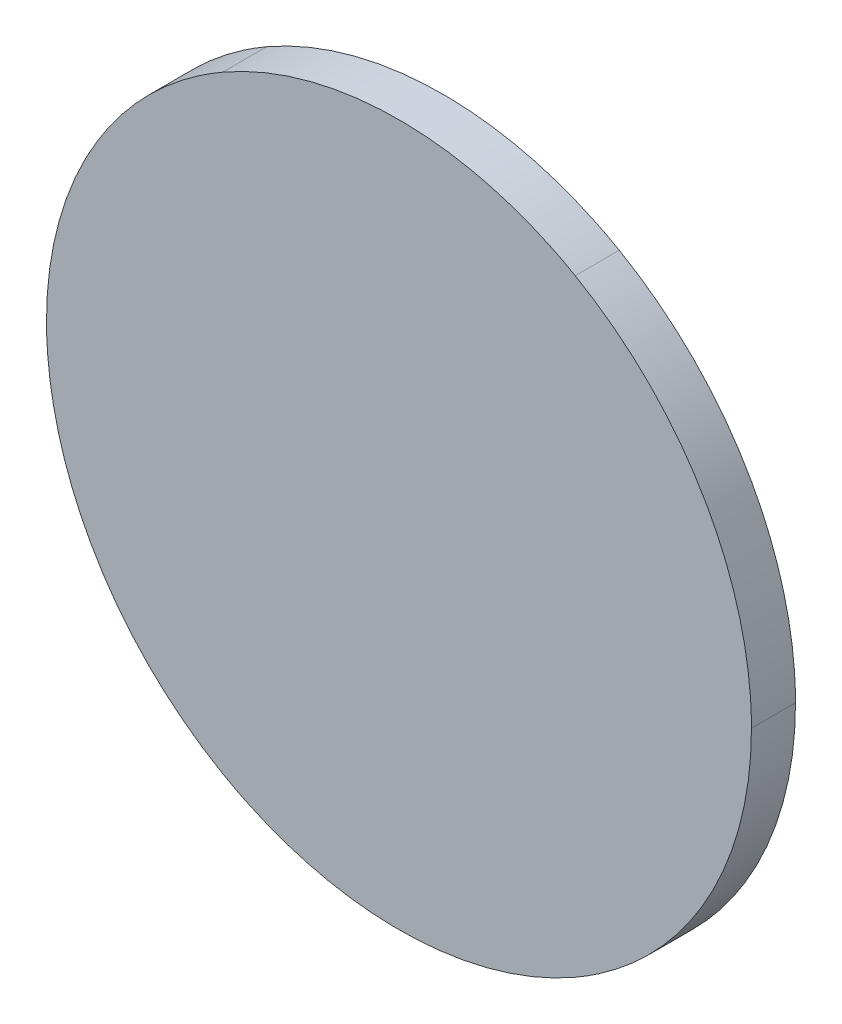
from build123d import *

# Parameters (mm, degrees)
BOSS_EXTRUDE1_DEPTH = 3.175
SKETCH3_R           = 22.596080088
BOSS_EXTRUDE2_DEPTH = 0.0254
DOME1_FACE_RADIUS   = 22.596080088
DOME1_HEIGHT        = 6.35
SKETCH4_R           = 15.615239036
CUT_EXTRUDE1_DEPTH  = 7.6454


with BuildPart() as part:
    # Sketch1 → Boss-Extrude1 (new body)
    with BuildSketch(Plane.XY):
        with BuildLine():
            add(Edge.make_bspline(
                [(50.828602384, 7910.062180707), (50.828602053, 7901.026169372), (45.984663658, 7892.676550548), (38.121451499, 7888.158544715)],
                knots=[0, 0, 0, 0, 1, 1, 1, 1], degree=3))
            add(Edge.make_bspline(
                [(38.121451499, 7888.158544715), (30.258239339, 7883.640539048), (20.570362548, 7883.640539048), (12.707150389, 7888.158544715)],
                knots=[0, 0, 0, 0, 1, 1, 1, 1], degree=3))
            add(Edge.make_bspline(
                [(12.707150389, 7888.158544715), (4.84393823, 7892.676550548), (-1.66e-07, 7901.026169372), (1.66e-07, 7910.062180707)],
                knots=[0, 0, 0, 0, 1, 1, 1, 1], degree=3))
            add(Edge.make_bspline(
                [(1.66e-07, 7910.062180707), (1.66e-07, 7919.098192041), (4.843938561, 7927.447810866), (12.70715072, 7931.965816533)],
                knots=[0, 0, 0, 0, 1, 1, 1, 1], degree=3))
            add(Edge.make_bspline(
                [(12.70715072, 7931.965816533), (20.570362879, 7936.4838222), (30.25823967, 7936.4838222), (38.12145183, 7931.965816533)],
                knots=[0, 0, 0, 0, 1, 1, 1, 1], degree=3))
            add(Edge.make_bspline(
                [(38.12145183, 7931.965816533), (45.984663989, 7927.447810866), (50.828602384, 7919.098192041), (50.828602384, 7910.062180707)],
                knots=[0, 0, 0, 0, 1, 1, 1, 1], degree=3))
        make_face()
    extrude(amount=BOSS_EXTRUDE1_DEPTH)

    # Sketch3 → Boss-Extrude2 (add)
    with BuildSketch(Plane.XY):
        with Locations((25.414301275, 7910.062180707)):
            Circle(SKETCH3_R)
    extrude(amount=-BOSS_EXTRUDE2_DEPTH)

    # Dome1: a dome of height H over a round flat face of radius A is a cap of a sphere of radius (A * A + H * H) / (2 * H)
    dome1_r = (DOME1_FACE_RADIUS * DOME1_FACE_RADIUS + DOME1_HEIGHT * DOME1_HEIGHT) / (2 * DOME1_HEIGHT)
    dome1_base = Plane((25.414301275, 7910.062180707, -0.0254), z_dir=(0, 0, -1))
    with Locations(dome1_base.offset(DOME1_HEIGHT - dome1_r)):
        dome1_ball = Sphere(dome1_r, mode=Mode.PRIVATE)
    add(split(dome1_ball, bisect_by=dome1_base, keep=Keep.TOP, mode=Mode.PRIVATE))

    # Sketch4 → Cut-Extrude1 (cut)
    with BuildSketch(Plane.XY):
        with Locations((25.409073045, 7919.859985206)):
            Circle(SKETCH4_R)
        with BuildLine():
            Line((28.51760754, 7900.091765684), (28.494324255, 7895.893452368))
            add(Edge.make_bspline(
                [(28.494324255, 7895.893452368), (32.487462639, 7895.777439774), (36.195197067, 7896.275514066), (39.779692278, 7897.341394667)],
                knots=[0, 0, 0, 0, 1, 1, 1, 1], degree=3))
            add(Edge.make_bspline(
                [(39.779692278, 7897.341394667), (42.236438359, 7901.275546963), (43.39540576, 7905.766244587), (42.606935871, 7910.885075863)],
                knots=[0, 0, 0, 0, 1, 1, 1, 1], degree=3))
            add(Edge.make_bspline(
                [(42.606935871, 7910.885075863), (41.151916565, 7907.286794723), (36.579479185, 7902.130368587), (28.51760754, 7900.091765684)],
                knots=[0, 0, 0, 0, 1, 1, 1, 1], degree=3))
        make_face()
        with BuildLine():
            Line((22.24306336, 7900.114149944), (22.266408875, 7895.915841924))
            add(Edge.make_bspline(
                [(22.266408875, 7895.915841924), (18.262512647, 7895.79981609), (14.544790967, 7896.297898327), (10.950640012, 7897.363778928)],
                knots=[0, 0, 0, 0, 1, 1, 1, 1], degree=3))
            add(Edge.make_bspline(
                [(10.950640012, 7897.363778928), (8.487275043, 7901.297931223), (7.408160638, 7905.705876198), (8.198755615, 7910.824707474)],
                knots=[0, 0, 0, 0, 1, 1, 1, 1], degree=3))
            add(Edge.make_bspline(
                [(8.198755615, 7910.824707474), (9.657694086, 7907.226426334), (14.159473448, 7902.152752848), (22.24306336, 7900.114149944)],
                knots=[0, 0, 0, 0, 1, 1, 1, 1], degree=3))
        make_face()
    extrude(amount=-CUT_EXTRUDE1_DEPTH, mode=Mode.SUBTRACT)


solid = part.part
